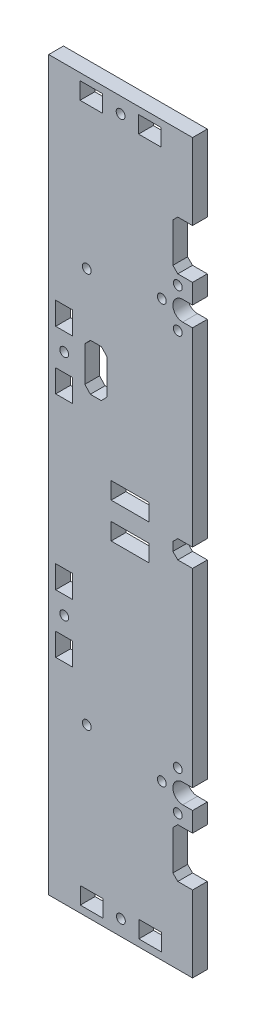
from build123d import *

# Parameters (mm, degrees)
MODEL_R                  = 1.8
MODEL_W                  = 9.199995837
MODEL_H                  = 6.900001917
MODEL_W_2                = 9.1999977
MODEL_W_3                = 15.39999384
MODEL_H_2                = 6.899997952
MODEL_W_4                = 6.900001918
MODEL_H_3                = 9.199995837
MODEL_H_4                = 9.1999977
MODEL_H_5                = 9.199997699
RESSALTO_EXTRUS_O1_DEPTH = 6


with BuildPart() as part:
    # Model → Ressalto-extrusão1 (new body)
    with BuildSketch(Plane.XY):
        with BuildLine():
            Line((89.771252514, 6.232071499), (31.271271234, 6.232071499))
            Line((31.271271234, 6.232071499), (31.271271234, 302.231976779))
            Line((31.271271234, 302.231976779), (89.771252514, 302.231976779))
            Line((89.771252514, 302.231976779), (89.771252514, 271.231986699))
            Line((89.771252514, 271.231986699), (83.771254434, 271.231986699))
            Line((83.771254434, 271.231986699), (81.771255074, 269.231987339))
            Line((81.771255074, 269.231987339), (81.771255074, 253.231992459))
            Line((81.771255074, 253.231992459), (83.771254434, 251.231993099))
            Line((83.771254434, 251.231993099), (89.771252514, 251.231993099))
            Line((89.771252514, 251.231993099), (89.771252514, 243.231995659))
            Line((89.771252514, 243.231995659), (85.771253794, 243.231995659))
            ThreePointArc((85.771253794, 243.231995659), (81.771255074, 239.231996939), (85.771253794, 235.231998219))
            Line((85.771253794, 235.231998219), (89.771252514, 235.231998219))
            Line((89.771252514, 235.231998219), (89.771252514, 157.982022859))
            Line((89.771252514, 157.982022859), (83.771254434, 157.982022859))
            Line((83.771254434, 157.982022859), (81.771255074, 155.982023499))
            Line((81.771255074, 155.982023499), (81.771255074, 152.482024779))
            Line((81.771255074, 152.482024779), (83.771254434, 150.482025419))
            Line((83.771254434, 150.482025419), (89.771252514, 150.482025419))
            Line((89.771252514, 150.482025419), (89.771252514, 73.232050059))
            Line((89.771252514, 73.232050059), (85.771253794, 73.232050059))
            ThreePointArc((85.771253794, 73.232050059), (81.771255074, 69.232051339), (85.771253794, 65.232052619))
            Line((85.771253794, 65.232052619), (89.771252514, 65.232052619))
            Line((89.771252514, 65.232052619), (89.771252514, 57.232055179))
            Line((89.771252514, 57.232055179), (83.771254434, 57.232055179))
            Line((83.771254434, 57.232055179), (81.771255074, 55.232055819))
            Line((81.771255074, 55.232055819), (81.771255074, 39.232060939))
            Line((81.771255074, 39.232060939), (83.771254434, 37.232061579))
            Line((83.771254434, 37.232061579), (89.771252514, 37.232061579))
            Line((89.771252514, 37.232061579), (89.771252514, 6.232071499))
        make_face()
        with Locations((60.621261842, 12.532070537)):
            Circle(MODEL_R, mode=Mode.SUBTRACT)
        with Locations((83.771254434, 61.233170309)):
            Circle(MODEL_R, mode=Mode.SUBTRACT)
        with Locations((77.271256514, 69.232051339)):
            Circle(MODEL_R, mode=Mode.SUBTRACT)
        with Locations((83.771254434, 77.232048779)):
            Circle(MODEL_R, mode=Mode.SUBTRACT)
        with Locations((46.771271234, 73.882024139)):
            Circle(MODEL_R, mode=Mode.SUBTRACT)
        with Locations((37.571269218, 107.832043016)):
            Circle(MODEL_R, mode=Mode.SUBTRACT)
        with Locations((37.571269218, 200.632005262)):
            Circle(MODEL_R, mode=Mode.SUBTRACT)
        with Locations((46.771271234, 234.582024139)):
            Circle(MODEL_R, mode=Mode.SUBTRACT)
        with Locations((83.771254434, 231.233115909)):
            Circle(MODEL_R, mode=Mode.SUBTRACT)
        with Locations((77.271256514, 239.231996939)):
            Circle(MODEL_R, mode=Mode.SUBTRACT)
        with Locations((83.771254434, 247.231994379)):
            Circle(MODEL_R, mode=Mode.SUBTRACT)
        with Locations((60.521261874, 295.931975819)):
            Circle(MODEL_R, mode=Mode.SUBTRACT)
        with Locations((72.521257893, 12.532071498)):
            Rectangle(MODEL_W, MODEL_H, mode=Mode.SUBTRACT)
        with Locations((48.621267095, 295.931976781)):
            Rectangle(MODEL_W_2, MODEL_H, mode=Mode.SUBTRACT)
        with Locations((64.371263002, 147.032026443)):
            Rectangle(MODEL_W_3, MODEL_H_2, mode=Mode.SUBTRACT)
        with Locations((37.571270179, 95.932046966)):
            Rectangle(MODEL_W_4, MODEL_H_3, mode=Mode.SUBTRACT)
        with Locations((72.421257924, 295.931976781)):
            Rectangle(MODEL_W, MODEL_H, mode=Mode.SUBTRACT)
        with Locations((37.571270179, 212.532000041)):
            Rectangle(MODEL_W_4, MODEL_H_4, mode=Mode.SUBTRACT)
        with Locations((37.571270179, 119.732037796)):
            Rectangle(MODEL_W_4, MODEL_H_5, mode=Mode.SUBTRACT)
        with Locations((48.721267063, 12.532071498)):
            Rectangle(MODEL_W_2, MODEL_H, mode=Mode.SUBTRACT)
        with Locations((37.571270179, 188.732009212)):
            Rectangle(MODEL_W_4, MODEL_H_3, mode=Mode.SUBTRACT)
        with Locations((64.371263002, 161.432021835)):
            Rectangle(MODEL_W_3, MODEL_H_2, mode=Mode.SUBTRACT)
        Polygon((54.919245732, 207.685602791), (52.679245732, 210.065602791), (48.199248599, 210.065602791), (45.959248599, 207.685602791), (45.959248599, 193.410404919), (48.199248599, 191.030404919), (52.679245732, 191.030404919), (54.919245732, 193.410404919), align=None, mode=Mode.SUBTRACT)
    extrude(amount=RESSALTO_EXTRUS_O1_DEPTH)


solid = part.part
